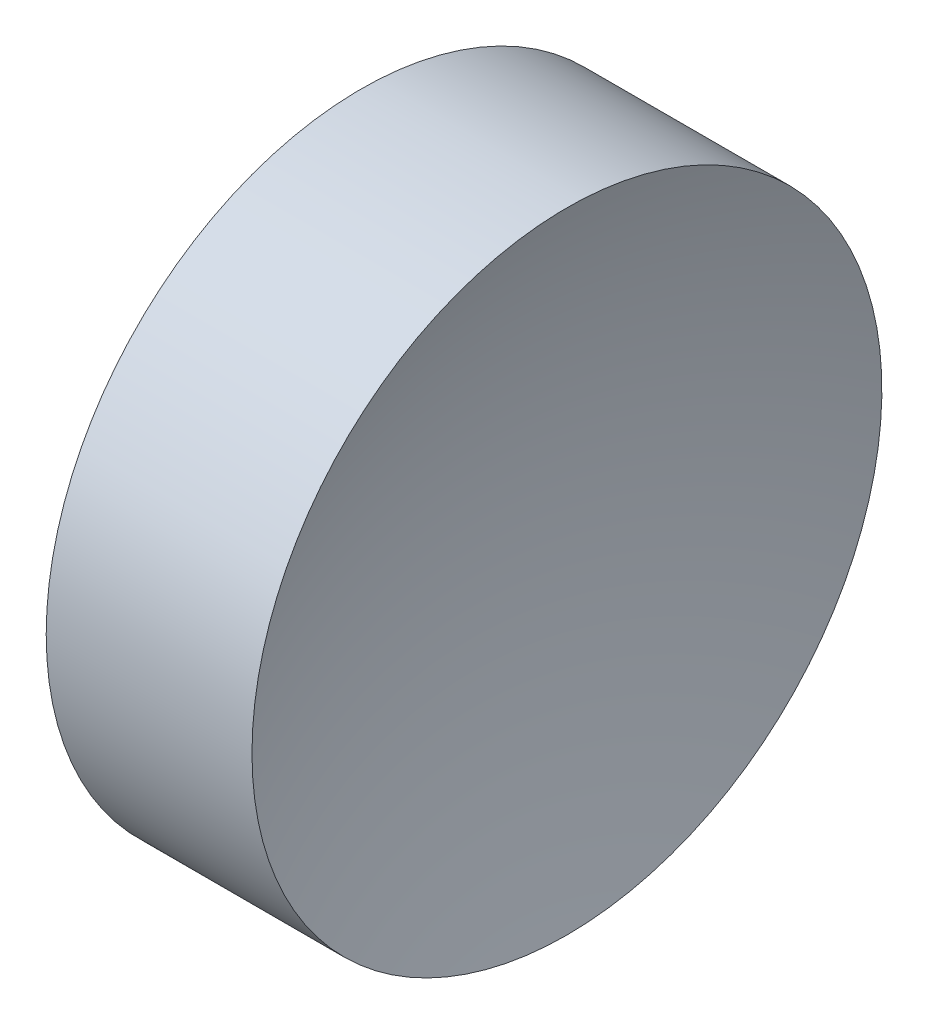
from build123d import *


with BuildPart() as part:
    # 草图2 → 旋转1 (revolve)
    with BuildSketch(Plane.XY, mode=Mode.PRIVATE) as revolve_1_sk:
        with BuildLine():
            Line((22.200875489, 13.031126091), (22.200875489, 16.181126091))
            Line((22.200875489, 16.181126091), (24.258883862, 16.181126091))
            ThreePointArc((24.258883862, 16.181126091), (23.841455162, 14.630647374), (23.700875501, 13.031126091))
            Line((23.700875501, 13.031126091), (22.200875489, 13.031126091))
        make_face()
    revolve(revolve_1_sk.sketch.rotate(Axis((21.156471922, 13.031126091, 0), (1, 0, 0)), 180), axis=Axis((21.156471922, 13.031126091, 0), (1, 0, 0)))  # turned: the seam where the file's is


solid = part.part
